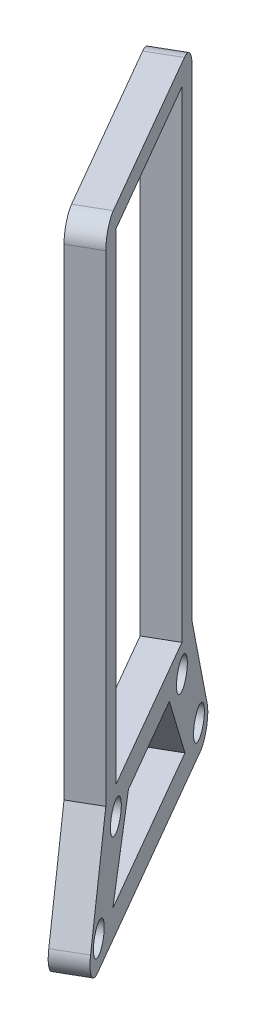
from build123d import *

# Parameters (mm, degrees)
SKETCH1_W           = 26.246666667
SKETCH1_H           = 70
SKETCH1_R           = 2.15
BOSS_EXTRUDE1_DEPTH = 4.45
FILLET1_R           = 3


with BuildPart() as part:
    # Sketch1 → Boss-Extrude1 (new body)
    with BuildSketch(Plane(origin=(7.062589735, 0, -4.077588085), x_dir=(0.5, 0, 0.866025404), z_dir=(-0.866025404, 0, 0.5))):
        Polygon((14.47543448, 209.798849573), (14.47543448, 136.798849573), (6.702101147, 118.055853922), (56.49543448, 118.055853922), (48.722101147, 136.798849573), (48.722101147, 209.798849573), align=None)
        with Locations((31.598767814, 171.798849573)):
            Rectangle(SKETCH1_W, SKETCH1_H, mode=Mode.SUBTRACT)
        with Locations((51.49543448, 122.055853922)):
            Circle(SKETCH1_R, mode=Mode.SUBTRACT)
        with Locations((44.722101147, 132.798849573)):
            Circle(SKETCH1_R, mode=Mode.SUBTRACT)
        with Locations((11.702101147, 122.055853922)):
            Circle(SKETCH1_R, mode=Mode.SUBTRACT)
        with Locations((18.47543448, 132.798849573)):
            Circle(SKETCH1_R, mode=Mode.SUBTRACT)
        Polygon((45.924572578, 122.055853922), (17.27296305, 122.055853922), (23.47543448, 132.798849573), (39.722101147, 132.798849573), align=None, mode=Mode.SUBTRACT)
    extrude(amount=-BOSS_EXTRUDE1_DEPTH)

    # Fillet1
    fillet1_edges = [part.edges().sort_by_distance(p)[0] for p in [
        (12.340546832, 118.055853922, 0.614101768),
        (37.237213499, 118.055853922, 43.736393373),
        (33.350546832, 209.798849573, 37.004489235),
        (16.227213499, 209.798849573, 7.346005906),
    ]]
    fillet(fillet1_edges, radius=FILLET1_R)


solid = part.part
